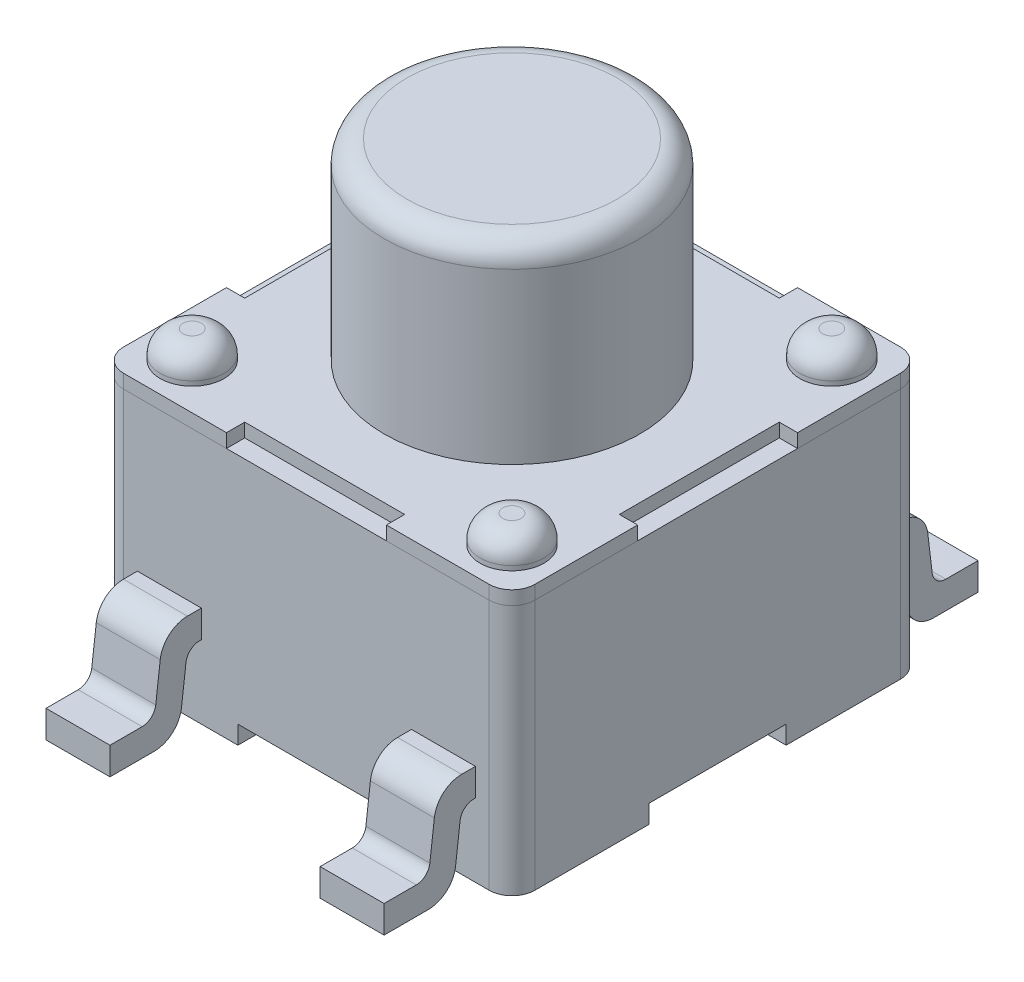
from build123d import *

# Parameters (mm, degrees)
BOSS_EXTRUDE1_DEPTH   = 2.75
BOSS_EXTRUDE4_DEPTH   = 0.15
SKETCH2_R             = 1.4
BOSS_EXTRUDE2_DEPTH   = 2.1
FILLET1_R             = 0.25
SKETCH3_R             = 0.35
BOSS_EXTRUDE3_DEPTH   = 0.3
BOSS_EXTRUDE3_2_DEPTH = 0.3
BOSS_EXTRUDE3_3_DEPTH = 0.3
BOSS_EXTRUDE3_4_DEPTH = 0.3
FILLET2_R             = 0.25
FILLET3_R             = 0.25
FILLET4_R             = 0.25
FILLET5_R             = 0.25
BOSS_EXTRUDE5_START   = 1.15
BOSS_EXTRUDE5_DEPTH   = 0.7
BOSS_EXTRUDE5_2_DEPTH = 0.7
BOSS_EXTRUDE6_START   = -1.15
BOSS_EXTRUDE6_DEPTH   = 0.7
CUT_EXTRUDE1_DEPTH    = 0.2


with BuildPart() as part:
    # Sketch1 → Boss-Extrude1 (new body)
    with BuildSketch(Plane(origin=(0, 0, 0), x_dir=(1, 0, 0), z_dir=(0, 1, 0))):
        with BuildLine():
            Line((-2, -2.25), (2, -2.25))
            ThreePointArc((2, -2.25), (2.176776695, -2.176776695), (2.25, -2))
            Line((2.25, -2), (2.25, 2))
            ThreePointArc((2.25, 2), (2.176776695, 2.176776695), (2, 2.25))
            Line((2, 2.25), (-2, 2.25))
            ThreePointArc((-2, 2.25), (-2.176776695, 2.176776695), (-2.25, 2))
            Line((-2.25, 2), (-2.25, -2))
            ThreePointArc((-2.25, -2), (-2.176776695, -2.176776695), (-2, -2.25))
        make_face()
    extrude(amount=BOSS_EXTRUDE1_DEPTH)

    # Sketch5_4 → Boss-Extrude6 (add)
    with BuildSketch(Plane.ZY.offset(BOSS_EXTRUDE6_START)):
        with BuildLine():
            Line((2.402218621, 1.1), (2.25, 1.1))
            Line((2.25, 1.1), (2.25, 0.8))
            Line((2.25, 0.8), (2.269271972, 0.8))
            ThreePointArc((2.269271972, 0.8), (2.36876479, 0.762254974), (2.418186155, 0.668015724))
            Line((2.418186155, 0.668015724), (2.467068014, 0.263968553))
            ThreePointArc((2.467068014, 0.263968553), (2.565910744, 0.075490051), (2.764896379, 0))
            Line((2.764896379, 0), (3.25, 0))
            Line((3.25, 0), (3.25, 0.3))
            Line((3.25, 0.3), (2.897843027, 0.3))
            ThreePointArc((2.897843027, 0.3), (2.79835021, 0.337745026), (2.748928845, 0.431984276))
            Line((2.748928845, 0.431984276), (2.700046986, 0.836031447))
            ThreePointArc((2.700046986, 0.836031447), (2.601204256, 1.024509949), (2.402218621, 1.1))
        make_face()
        with BuildLine():
            Line((-2.25, 0.8), (-2.25, 1.1))
            Line((-2.25, 1.1), (-2.402218621, 1.1))
            ThreePointArc((-2.402218621, 1.1), (-2.601204256, 1.024509949), (-2.700046986, 0.836031447))
            Line((-2.700046986, 0.836031447), (-2.748928845, 0.431984276))
            ThreePointArc((-2.748928845, 0.431984276), (-2.79835021, 0.337745026), (-2.897843027, 0.3))
            Line((-2.897843027, 0.3), (-3.25, 0.3))
            Line((-3.25, 0.3), (-3.25, 0))
            Line((-3.25, 0), (-2.764896379, 0))
            ThreePointArc((-2.764896379, 0), (-2.565910744, 0.075490051), (-2.467068014, 0.263968553))
            Line((-2.467068014, 0.263968553), (-2.418186155, 0.668015724))
            ThreePointArc((-2.418186155, 0.668015724), (-2.36876479, 0.762254974), (-2.269271972, 0.8))
            Line((-2.269271972, 0.8), (-2.25, 0.8))
        make_face()
    extrude(amount=-BOSS_EXTRUDE6_DEPTH)

    # Sketch7 → Cut-Extrude1 (cut)
    with BuildSketch(Plane.XZ):
        Polygon((-2.25, -0.75), (-0.75, -0.75), (-0.75, -2.25), (0.75, -2.25), (0.75, -0.75), (2.25, -0.75), (2.25, 0.75), (0.75, 0.75), (0.75, 2.25), (-0.75, 2.25), (-0.75, 0.75), (-2.25, 0.75), align=None)
    extrude(amount=-CUT_EXTRUDE1_DEPTH, mode=Mode.SUBTRACT)


with BuildPart() as body_2:
    # Sketch4 → Boss-Extrude4 (new body)
    with BuildSketch(Plane(origin=(0, 2.75, 0), x_dir=(1, 0, 0), z_dir=(0, 1, 0))):
        with BuildLine():
            Line((2, 2.25), (0.875, 2.25))
            Line((0.875, 2.25), (0.875, 2.05))
            Line((0.875, 2.05), (-0.875, 2.05))
            Line((-0.875, 2.05), (-0.875, 2.25))
            Line((-0.875, 2.25), (-2, 2.25))
            ThreePointArc((-2, 2.25), (-2.176776695, 2.176776695), (-2.25, 2))
            Line((-2.25, 2), (-2.25, 0.875))
            Line((-2.25, 0.875), (-2.05, 0.875))
            Line((-2.05, 0.875), (-2.05, -0.875))
            Line((-2.05, -0.875), (-2.25, -0.875))
            Line((-2.25, -0.875), (-2.25, -2))
            ThreePointArc((-2.25, -2), (-2.176776695, -2.176776695), (-2, -2.25))
            Line((-2, -2.25), (-0.875, -2.25))
            Line((-0.875, -2.25), (-0.875, -2.05))
            Line((-0.875, -2.05), (0.875, -2.05))
            Line((0.875, -2.05), (0.875, -2.25))
            Line((0.875, -2.25), (2, -2.25))
            ThreePointArc((2, -2.25), (2.176776695, -2.176776695), (2.25, -2))
            Line((2.25, -2), (2.25, -0.875))
            Line((2.25, -0.875), (2.05, -0.875))
            Line((2.05, -0.875), (2.05, 0.875))
            Line((2.05, 0.875), (2.25, 0.875))
            Line((2.25, 0.875), (2.25, 2))
            ThreePointArc((2.25, 2), (2.176776695, 2.176776695), (2, 2.25))
        make_face()
    extrude(amount=BOSS_EXTRUDE4_DEPTH)


with BuildPart() as body_3:
    # Sketch2 → Boss-Extrude2 (new body)
    with BuildSketch(Plane(origin=(0, 2.9, 0), x_dir=(1, 0, 0), z_dir=(0, 1, 0))):
        Circle(SKETCH2_R)
    extrude(amount=BOSS_EXTRUDE2_DEPTH)

    # Fillet1
    fillet1_edges = [body_3.edges().sort_by_distance(p)[0] for p in [
        (-1.4, 5, 0),
    ]]
    fillet(fillet1_edges, radius=FILLET1_R)


with BuildPart() as body_4:
    # Sketch3 → Boss-Extrude3 (new body)
    with BuildSketch(Plane(origin=(0, 2.9, 0), x_dir=(1, 0, 0), z_dir=(0, 1, 0))):
        with Locations((-1.75, -1.75)):
            Circle(SKETCH3_R)
    extrude(amount=BOSS_EXTRUDE3_DEPTH)

    # Fillet4
    fillet4_edges = [body_4.edges().sort_by_distance(p)[0] for p in [
        (-2.1, 3.2, 1.75),
    ]]
    fillet(fillet4_edges, radius=FILLET4_R)


with BuildPart() as body_5:
    # Sketch3 → Boss-Extrude3 2 (new body)
    with BuildSketch(Plane(origin=(0, 2.9, 0), x_dir=(1, 0, 0), z_dir=(0, 1, 0))):
        with Locations((1.75, -1.75)):
            Circle(SKETCH3_R)
    extrude(amount=BOSS_EXTRUDE3_2_DEPTH)

    # Fillet5
    fillet5_edges = [body_5.edges().sort_by_distance(p)[0] for p in [
        (1.4, 3.2, 1.75),
    ]]
    fillet(fillet5_edges, radius=FILLET5_R)


with BuildPart() as body_6:
    # Sketch3 → Boss-Extrude3 3 (new body)
    with BuildSketch(Plane(origin=(0, 2.9, 0), x_dir=(1, 0, 0), z_dir=(0, 1, 0))):
        with Locations((1.75, 1.75)):
            Circle(SKETCH3_R)
    extrude(amount=BOSS_EXTRUDE3_3_DEPTH)

    # Fillet2
    fillet2_edges = [body_6.edges().sort_by_distance(p)[0] for p in [
        (1.4, 3.2, -1.75),
    ]]
    fillet(fillet2_edges, radius=FILLET2_R)


with BuildPart() as body_7:
    # Sketch3 → Boss-Extrude3 4 (new body)
    with BuildSketch(Plane(origin=(0, 2.9, 0), x_dir=(1, 0, 0), z_dir=(0, 1, 0))):
        with Locations((-1.75, 1.75)):
            Circle(SKETCH3_R)
    extrude(amount=BOSS_EXTRUDE3_4_DEPTH)

    # Fillet3
    fillet3_edges = [body_7.edges().sort_by_distance(p)[0] for p in [
        (-2.1, 3.2, -1.75),
    ]]
    fillet(fillet3_edges, radius=FILLET3_R)


with BuildPart() as body_8:
    # Sketch5 → Boss-Extrude5 (new body)
    with BuildSketch(Plane.ZY.offset(BOSS_EXTRUDE5_START)):
        with BuildLine():
            Line((2.402218621, 1.1), (2.25, 1.1))
            Line((2.25, 1.1), (2.25, 0.8))
            Line((2.25, 0.8), (2.269271972, 0.8))
            ThreePointArc((2.269271972, 0.8), (2.36876479, 0.762254974), (2.418186155, 0.668015724))
            Line((2.418186155, 0.668015724), (2.467068014, 0.263968553))
            ThreePointArc((2.467068014, 0.263968553), (2.565910744, 0.075490051), (2.764896379, 0))
            Line((2.764896379, 0), (3.25, 0))
            Line((3.25, 0), (3.25, 0.3))
            Line((3.25, 0.3), (2.897843027, 0.3))
            ThreePointArc((2.897843027, 0.3), (2.79835021, 0.337745026), (2.748928845, 0.431984276))
            Line((2.748928845, 0.431984276), (2.700046986, 0.836031447))
            ThreePointArc((2.700046986, 0.836031447), (2.601204256, 1.024509949), (2.402218621, 1.1))
        make_face()
    extrude(amount=BOSS_EXTRUDE5_DEPTH)


with BuildPart() as body_9:
    # Sketch5 → Boss-Extrude5 2 (new body)
    with BuildSketch(Plane.ZY.offset(BOSS_EXTRUDE5_START)):
        with BuildLine():
            Line((-2.25, 0.8), (-2.25, 1.1))
            Line((-2.25, 1.1), (-2.402218621, 1.1))
            ThreePointArc((-2.402218621, 1.1), (-2.601204256, 1.024509949), (-2.700046986, 0.836031447))
            Line((-2.700046986, 0.836031447), (-2.748928845, 0.431984276))
            ThreePointArc((-2.748928845, 0.431984276), (-2.79835021, 0.337745026), (-2.897843027, 0.3))
            Line((-2.897843027, 0.3), (-3.25, 0.3))
            Line((-3.25, 0.3), (-3.25, 0))
            Line((-3.25, 0), (-2.764896379, 0))
            ThreePointArc((-2.764896379, 0), (-2.565910744, 0.075490051), (-2.467068014, 0.263968553))
            Line((-2.467068014, 0.263968553), (-2.418186155, 0.668015724))
            ThreePointArc((-2.418186155, 0.668015724), (-2.36876479, 0.762254974), (-2.269271972, 0.8))
            Line((-2.269271972, 0.8), (-2.25, 0.8))
        make_face()
    extrude(amount=BOSS_EXTRUDE5_2_DEPTH)


solid = Compound([part.part, body_2.part, body_3.part, body_4.part, body_5.part, body_6.part, body_7.part, body_8.part, body_9.part])
